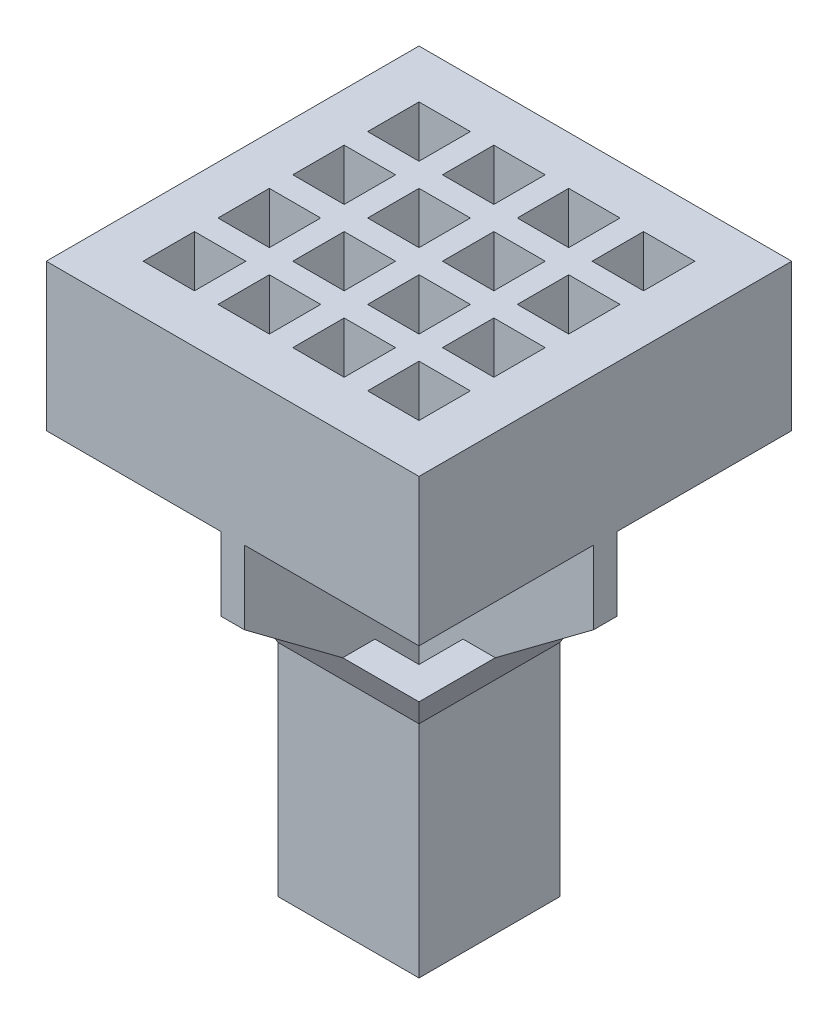
from build123d import *

# Parameters (mm, degrees)
TOP_PANEL_W            = 2.54
TOP_PANEL_H            = 2.54
BOSS_EXTRUDE1_DEPTH    = 1
WELL_HOLES_W           = 0.35
WELL_HOLES_H           = 0.35
WELLS_DEPTH            = 1
SKETCH5_W              = 2.54
SKETCH5_H              = 0.16
BOSS_EXTRUDE5_DEPTH    = 0.5
SKETCH4_W              = 1.2
SKETCH4_H              = 0.16
SUPPORT_WALL_SKETCH_W  = 0.16
SUPPORT_WALL_SKETCH_H  = 2.54
BOSS_EXTRUDE7_DEPTH    = 0.5
SKETCH7_W              = 0.16
SKETCH7_H              = 0.52
SKETCH7_3_W            = 0.16
SKETCH7_3_H            = 0.52
SKETCH8_W              = 1.2
SKETCH8_H              = 1.2
SKETCH9_W              = 0.96
SKETCH9_H              = 0.96
SKETCH9_2_W            = 0.96
SKETCH9_2_H            = 0.96
BOSS_EXTRUDE8_DEPTH    = 1.5
TETRODE_ENTRY_HOLDES_W = 0.3
TETRODE_ENTRY_HOLDES_H = 0.3
CUT_EXTRUDE1_DEPTH     = 1.75


with BuildPart() as part:
    # top_panel → Boss-Extrude1 (new body)
    with BuildSketch(Plane(origin=(0, 0, 0), x_dir=(1, 0, 0), z_dir=(0, 1, 0))):
        with Locations((-17.144369017, 12.374381862)):
            Rectangle(TOP_PANEL_W, TOP_PANEL_H)
    extrude(amount=-BOSS_EXTRUDE1_DEPTH)

    # well_holes → wells (cut)
    with BuildSketch(Plane(origin=(0, 0, 0), x_dir=(1, 0, 0), z_dir=(0, 1, 0))):
        with Locations((-17.399369017, 13.139381862)):
            Rectangle(WELL_HOLES_W, WELL_HOLES_H)
        with Locations((-17.909369017, 13.139381862)):
            Rectangle(WELL_HOLES_W, WELL_HOLES_H)
        with Locations((-16.889369017, 13.139381862)):
            Rectangle(WELL_HOLES_W, WELL_HOLES_H)
        with Locations((-16.379369017, 13.139381862)):
            Rectangle(WELL_HOLES_W, WELL_HOLES_H)
        with Locations((-17.399369017, 12.629381862)):
            Rectangle(WELL_HOLES_W, WELL_HOLES_H)
        with Locations((-16.889369017, 12.629381862)):
            Rectangle(WELL_HOLES_W, WELL_HOLES_H)
        with Locations((-16.379369017, 12.629381862)):
            Rectangle(WELL_HOLES_W, WELL_HOLES_H)
        with Locations((-17.399369017, 12.119381862)):
            Rectangle(WELL_HOLES_W, WELL_HOLES_H)
        with Locations((-16.889369017, 12.119381862)):
            Rectangle(WELL_HOLES_W, WELL_HOLES_H)
        with Locations((-16.379369017, 12.119381862)):
            Rectangle(WELL_HOLES_W, WELL_HOLES_H)
        with Locations((-17.399369017, 11.609381862)):
            Rectangle(WELL_HOLES_W, WELL_HOLES_H)
        with Locations((-16.889369017, 11.609381862)):
            Rectangle(WELL_HOLES_W, WELL_HOLES_H)
        with Locations((-16.379369017, 11.609381862)):
            Rectangle(WELL_HOLES_W, WELL_HOLES_H)
        with Locations((-17.909369017, 12.629381862)):
            Rectangle(WELL_HOLES_W, WELL_HOLES_H)
        with Locations((-17.909369017, 12.119381862)):
            Rectangle(WELL_HOLES_W, WELL_HOLES_H)
        with Locations((-17.909369017, 11.609381862)):
            Rectangle(WELL_HOLES_W, WELL_HOLES_H)
    extrude(amount=-WELLS_DEPTH, mode=Mode.SUBTRACT)

    # Sketch5 → Boss-Extrude5 (add)
    with BuildSketch(Plane(origin=(0, -1, 0), x_dir=(-1, 0, 0), z_dir=(0, -1, 0))):
        with Locations((17.144369017, 12.374381862)):
            Rectangle(SKETCH5_W, SKETCH5_H)
    extrude(amount=BOSS_EXTRUDE5_DEPTH)

    # Sketch4 → section 1 of loft3
    with BuildSketch(Plane(origin=(0, -2, 0), x_dir=(1, 0, 0), z_dir=(0, 1, 0)), mode=Mode.PRIVATE) as loft3_s1:
        with Locations((-17.144369017, 12.374381862)):
            Rectangle(SKETCH4_W, SKETCH4_H)
    # loft from a face of the part (loft3)
    loft([part.faces().sort_by_distance((-17.144369017, -1.5, -12.374381862))[0], loft3_s1.sketch])

    # support_wall_sketch → Boss-Extrude7 (add)
    with BuildSketch(Plane(origin=(0, -1, 0), x_dir=(-1, 0, 0), z_dir=(0, -1, 0))):
        with Locations((17.144369017, 12.374381862)):
            Rectangle(SUPPORT_WALL_SKETCH_W, SUPPORT_WALL_SKETCH_H)
    extrude(amount=BOSS_EXTRUDE7_DEPTH)

    # Sketch7 → section 1 of loft6
    with BuildSketch(Plane(origin=(0, -2, 0), x_dir=(1, 0, 0), z_dir=(0, 1, 0)), mode=Mode.PRIVATE) as loft6_s1:
        with Locations((-17.144369017, 12.034381862)):
            Rectangle(SKETCH7_W, SKETCH7_H)
    # loft from a face of the part (loft6)
    loft([part.faces().sort_by_distance((-17.144369017, -1.5, -11.699381862))[0], loft6_s1.sketch])

    # Sketch7_3 → section 1 of loft7
    with BuildSketch(Plane(origin=(0, -2, 0), x_dir=(1, 0, 0), z_dir=(0, 1, 0)), mode=Mode.PRIVATE) as loft7_s1:
        with Locations((-17.144369017, 12.714381862)):
            Rectangle(SKETCH7_3_W, SKETCH7_3_H)
    # loft from a face of the part (loft7)
    loft([part.faces().sort_by_distance((-17.144369017, -1.5, -13.049381862))[0], loft7_s1.sketch])

    # Sketch8 → Loft8 section 0
    with BuildSketch(Plane(origin=(0, -2, 0), x_dir=(1, 0, 0), z_dir=(0, 1, 0))):
        with Locations((-17.144369017, 12.374381862)):
            Rectangle(SKETCH8_W, SKETCH8_H)
    # Sketch9 → Loft8 section 1
    with BuildSketch(Plane(origin=(0, -2.25, 0), x_dir=(1, 0, 0), z_dir=(0, 1, 0))):
        with Locations((-17.144369017, 12.374381862)):
            Rectangle(SKETCH9_W, SKETCH9_H)
    loft()

    # Sketch9_2 → Boss-Extrude8 (add)
    with BuildSketch(Plane(origin=(0, -2.25, 0), x_dir=(1, 0, 0), z_dir=(0, 1, 0))):
        with Locations((-17.144369017, 12.374381862)):
            Rectangle(SKETCH9_2_W, SKETCH9_2_H)
    extrude(amount=-BOSS_EXTRUDE8_DEPTH)

    # tetrode_entry_holdes → Cut-Extrude1 (cut)
    with BuildSketch(Plane(origin=(0, -2, 0), x_dir=(1, 0, 0), z_dir=(0, 1, 0))):
        with Locations((-17.374369017, 12.144381862)):
            Rectangle(TETRODE_ENTRY_HOLDES_W, TETRODE_ENTRY_HOLDES_H)
        with Locations((-16.914369017, 12.144381862)):
            Rectangle(TETRODE_ENTRY_HOLDES_W, TETRODE_ENTRY_HOLDES_H)
        with Locations((-16.914369017, 12.604381862)):
            Rectangle(TETRODE_ENTRY_HOLDES_W, TETRODE_ENTRY_HOLDES_H)
        with Locations((-17.374369017, 12.604381862)):
            Rectangle(TETRODE_ENTRY_HOLDES_W, TETRODE_ENTRY_HOLDES_H)
    extrude(amount=-CUT_EXTRUDE1_DEPTH, mode=Mode.SUBTRACT)


solid = part.part
